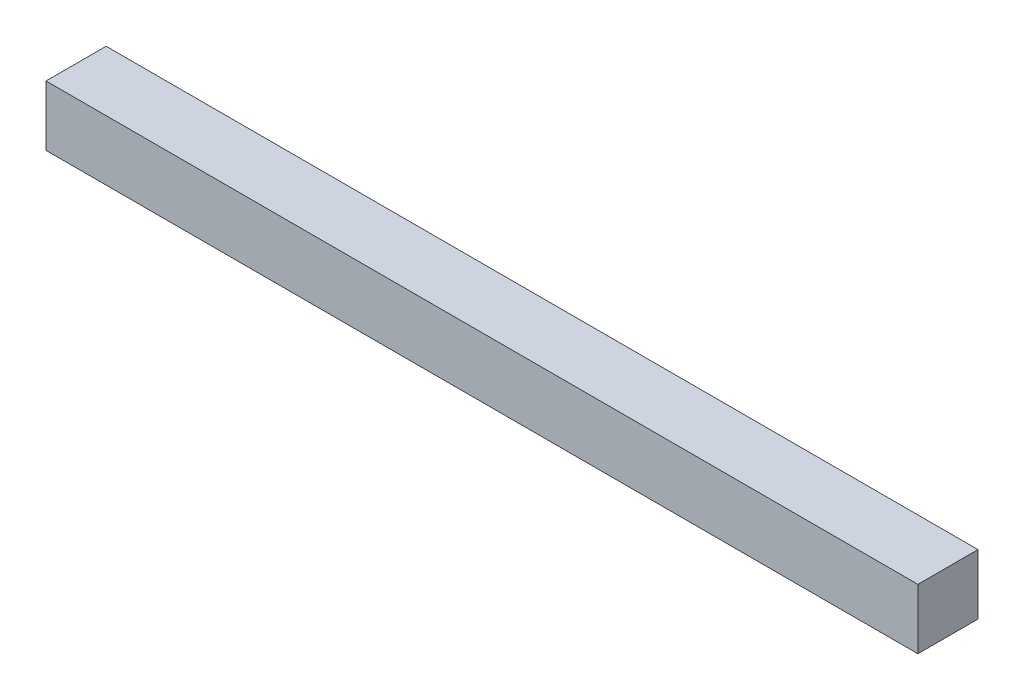
from build123d import *

# Parameters (mm, degrees)
SKETCH1_W           = 46.03496
SKETCH1_H           = 3.175
BOSS_EXTRUDE1_DEPTH = 3.175


with BuildPart() as part:
    # Sketch1 → Boss-Extrude1 (new body)
    with BuildSketch(Plane(origin=(0, 0, 0), x_dir=(1, 0, 0), z_dir=(0, 1, 0))):
        with Locations((-23.01748, 1.5875)):
            Rectangle(SKETCH1_W, SKETCH1_H)
    extrude(amount=BOSS_EXTRUDE1_DEPTH)


solid = part.part
